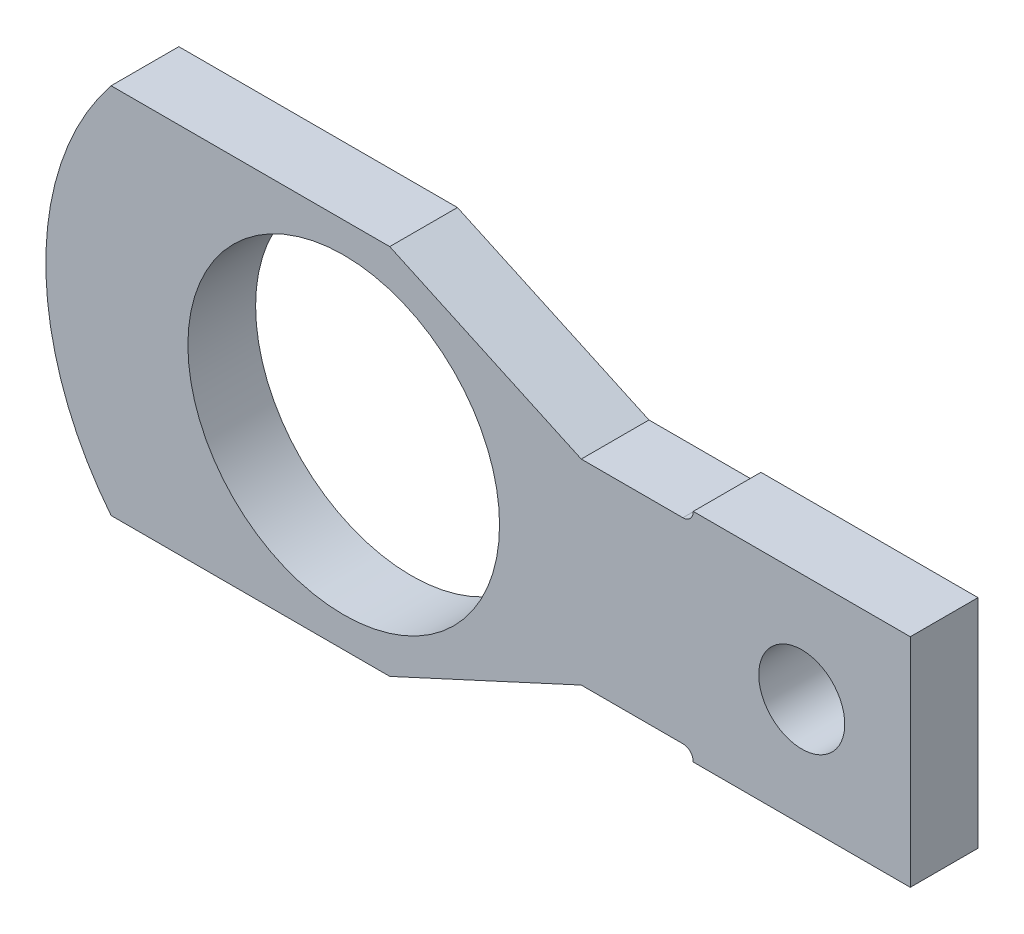
from build123d import *

# Parameters (mm, degrees)
CROQUIS1_R                   = 115.062
CROQUIS1_R_2                 = 31.75
SALIENTE_EXTRUIR1_DEPTH      = 50
CORPS_D_PLACER_COPIER1_ANGLE = 90


with BuildPart() as part:
    # Croquis1 → Saliente-Extruir1 (new body)
    with BuildSketch(Plane.XY):
        with BuildLine():
            Line((-72.263, -175.395747529), (-72.263, -249.055747529))
            Line((-72.263, -249.055747529), (-72.263, -250.444))
            ThreePointArc((-72.263, -250.444), (-74.494846327, -255.832153673), (-79.883, -258.064))
            Line((-79.883, -258.064), (-80.137, -258.064))
            Line((-80.137, -258.064), (-80.137, -418.338))
            Line((-80.137, -418.338), (80.137, -418.338))
            Line((80.137, -418.338), (80.137, -258.064))
            Line((80.137, -258.064), (79.883, -258.064))
            ThreePointArc((79.883, -258.064), (74.494846327, -255.832153673), (72.263, -250.444))
            Line((72.263, -250.444), (72.263, -249.055747529))
            Line((72.263, -249.055747529), (72.263, -175.395747529))
            Line((72.263, -175.395747529), (137.414, -33.979836109))
            Line((137.414, -33.979836109), (137.414, 171.760163891))
            ThreePointArc((137.414, 171.760163891), (0, 219.964), (-137.414, 171.760163891))
            Line((-137.414, 171.760163891), (-137.414, -33.979836109))
            Line((-137.414, -33.979836109), (-72.263, -175.395747529))
        make_face()
        Circle(CROQUIS1_R, mode=Mode.SUBTRACT)
        with Locations((0, -338.201)):
            Circle(CROQUIS1_R_2, mode=Mode.SUBTRACT)
    extrude(amount=SALIENTE_EXTRUIR1_DEPTH)


with BuildPart() as part_1:
    # Corps-Déplacer/Copier1: moved
    add(part.part.rotate(Axis((0, 0, 0), (0, 0, 1)), CORPS_D_PLACER_COPIER1_ANGLE))


solid = part_1.part
